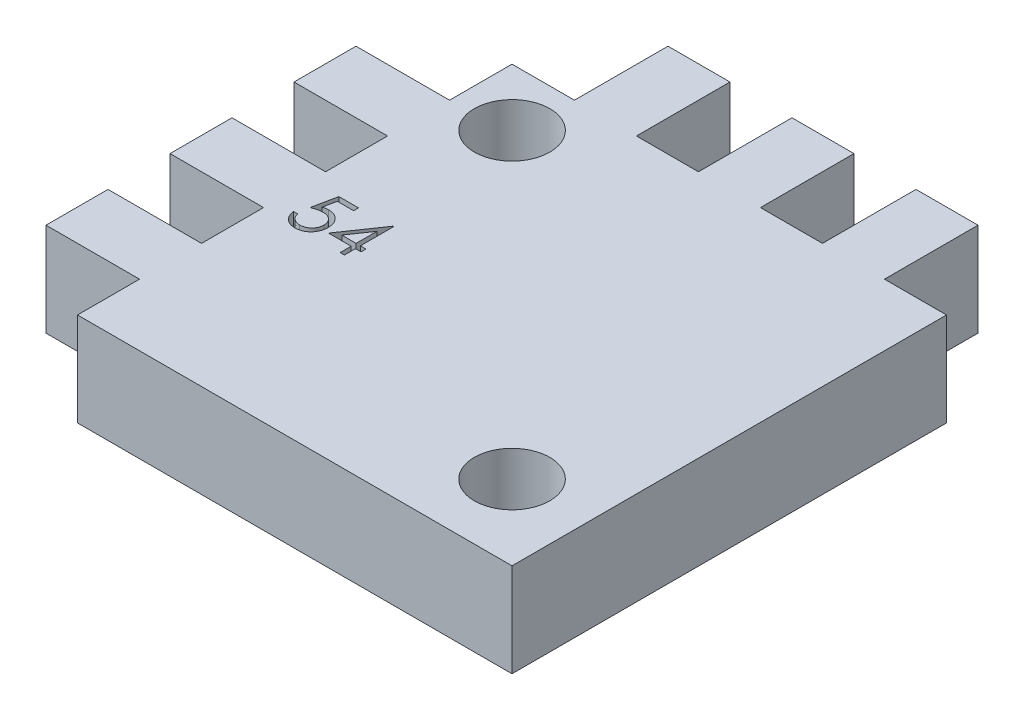
from build123d import *

# Parameters (mm, degrees)
SKETCH1_R           = 2.5
BOSS_EXTRUDE1_DEPTH = 6.2
CUT_EXTRUDE1_DEPTH  = 1


with BuildPart() as part:
    # Sketch1 → Boss-Extrude1 (new body)
    with BuildSketch(Plane(origin=(0, 0, 0), x_dir=(1, 0, 0), z_dir=(0, 1, 0))):
        Polygon((0, 24.66), (0, 20.55), (6.2, 20.55), (6.2, 16.44), (0, 16.44), (0, 12.33), (6.2, 12.33), (6.2, 8.22), (0, 8.22), (0, 4.11), (6.2, 4.11), (6.2, 0), (17, 0), (35, 0), (35, 18), (35, 28.8), (30.89, 28.8), (30.89, 35), (26.78, 35), (26.78, 28.8), (22.67, 28.8), (22.67, 35), (18.56, 35), (18.56, 28.8), (14.45, 28.8), (14.45, 35), (10.34, 35), (10.34, 28.8), (6.2, 28.8), (6.2, 24.66), align=None)
        with Locations((10.006, 25)):
            Circle(SKETCH1_R, mode=Mode.SUBTRACT)
        with Locations((30.02235364, 4.980572344)):
            Circle(SKETCH1_R, mode=Mode.SUBTRACT)
    extrude(amount=BOSS_EXTRUDE1_DEPTH)

    # Sketch2 → Cut-Extrude1 (cut)
    with BuildSketch(Plane(origin=(0, 6.2, 0), x_dir=(1, 0, 0), z_dir=(0, 1, 0))):
        with BuildLine():
            Line((9.367624272, 15.46006193), (9.367624272, 15.134420905))
            Line((9.367624272, 15.134420905), (8.28766634, 15.134420905))
            Line((8.28766634, 15.134420905), (8.116577598, 14.299329759))
            add(Edge.make_bspline(
                [(8.116577598, 14.299329759), (8.150192569, 14.308610077), (8.215316261, 14.326589225), (8.311436992, 14.346551603), (8.40268849, 14.358585256), (8.461902576, 14.360228373), (8.490555963, 14.361023469)],
                knots=[0, 0, 0, 0, 0.000104595, 0.000202637, 0.000294305, 0.000380252, 0.000380252, 0.000380252, 0.000380252], degree=3))
            add(Edge.make_bspline(
                [(8.490555963, 14.361023469), (8.526010498, 14.360256084), (8.595722973, 14.358747215), (8.697721161, 14.344258466), (8.795087428, 14.321452972), (8.88761815, 14.289593641), (8.975484506, 14.248854097), (9.05787808, 14.197963437), (9.136035615, 14.138515344), (9.208554968, 14.070166655), (9.274344876, 13.994944902), (9.332189738, 13.914065976), (9.381322945, 13.828315883), (9.420838773, 13.736875331), (9.452393133, 13.640755241), (9.4733953, 13.538944256), (9.487380458, 13.432402033), (9.488942908, 13.359554316), (9.489739657, 13.322406682)],
                knots=[0, 0, 0, 0, 0.000106308, 0.000209029, 0.000308378, 0.000405929, 0.000502102, 0.000598312, 0.00069588, 0.000796219, 0.000896736, 0.000995218, 0.001094066, 0.001192613, 0.001293582, 0.001396995, 0.001504047, 0.001615439, 0.001615439, 0.001615439, 0.001615439], degree=3))
            add(Edge.make_bspline(
                [(9.489739657, 13.322406682), (9.489136339, 13.296532954), (9.487937855, 13.245135158), (9.481843137, 13.168804347), (9.470108594, 13.094089491), (9.454353587, 13.020980679), (9.433904394, 12.94961632), (9.409149323, 12.879792148), (9.378854356, 12.811942755), (9.345624465, 12.745426146), (9.308208017, 12.681746072), (9.266680371, 12.622193063), (9.222805961, 12.56587375), (9.17559699, 12.51339215), (9.124614659, 12.465093126), (9.070476403, 12.420690042), (9.013614223, 12.379431978), (8.953148396, 12.342993687), (8.890426286, 12.309463005), (8.824542118, 12.281955225), (8.756995625, 12.257362103), (8.686814631, 12.237759175), (8.614158101, 12.222398929), (8.538906269, 12.211966241), (8.461453804, 12.204367616), (8.4089529, 12.203891949), (8.382432966, 12.203651674)],
                knots=[0, 0, 0, 0, 7.7636e-05, 0.000154223, 0.000229512, 0.000304362, 0.000378447, 0.000452077, 0.000526407, 0.000601214, 0.00067506, 0.000747747, 0.00081887, 0.000889121, 0.000959302, 0.001029336, 0.001099058, 0.00116985, 0.001240974, 0.00131221, 0.00138383, 0.001456517, 0.001530612, 0.001606437, 0.001684346, 0.001763871, 0.001763871, 0.001763871, 0.001763871], degree=3))
            add(Edge.make_bspline(
                [(8.382432966, 12.203651674), (8.350797102, 12.204278363), (8.288557277, 12.205511299), (8.197370763, 12.218409496), (8.109636799, 12.236882477), (8.026061636, 12.264673951), (7.945896275, 12.299496711), (7.870219953, 12.343507809), (7.797098999, 12.393381711), (7.729505937, 12.452237459), (7.666771462, 12.516568114), (7.610613415, 12.586379688), (7.560599385, 12.660519968), (7.517530286, 12.739349008), (7.480792795, 12.822659675), (7.451932056, 12.910764112), (7.428638119, 13.003201972), (7.418783445, 13.066841228), (7.413778118, 13.099164495)],
                knots=[0, 0, 0, 0, 9.4843e-05, 0.000186593, 0.000275792, 0.000363484, 0.000450342, 0.000537514, 0.000625728, 0.000715478, 0.000805885, 0.000894984, 0.00098389, 0.001073836, 0.001164117, 0.001256635, 0.001351658, 0.001449737, 0.001449737, 0.001449737, 0.001449737], degree=3))
            Line((7.413778118, 13.099164495), (7.698714016, 13.099164495))
            add(Edge.make_bspline(
                [(7.698714016, 13.099164495), (7.705724921, 13.068887284), (7.719200271, 13.010692804), (7.748778343, 12.928930802), (7.784942388, 12.856069792), (7.827944904, 12.791145956), (7.87924386, 12.73453208), (7.93778127, 12.684079459), (8.003410991, 12.638563449), (8.076339135, 12.600624224), (8.153276714, 12.56826757), (8.233801254, 12.546721389), (8.315720197, 12.531571293), (8.371127004, 12.530054768), (8.398969424, 12.5292927)],
                knots=[0, 0, 0, 0, 9.3172e-05, 0.000179081, 0.000260145, 0.000336703, 0.000411917, 0.000488562, 0.000568128, 0.000650923, 0.00073478, 0.000817953, 0.000900557, 0.000983994, 0.000983994, 0.000983994, 0.000983994], degree=3))
            add(Edge.make_bspline(
                [(8.398969424, 12.5292927), (8.426146013, 12.530037262), (8.479656939, 12.531503313), (8.558407269, 12.542787274), (8.634437519, 12.560165928), (8.706997478, 12.586173582), (8.777356875, 12.617782719), (8.843735938, 12.658345681), (8.908054976, 12.705027269), (8.968314783, 12.758509355), (9.023504855, 12.817446149), (9.072269336, 12.880472071), (9.112888394, 12.947706638), (9.147118621, 13.017985856), (9.173111256, 13.092079975), (9.191654146, 13.169641756), (9.202542635, 13.250862773), (9.204040492, 13.306261362), (9.204803759, 13.334491017)],
                knots=[0, 0, 0, 0, 8.15e-05, 0.000160473, 0.000238226, 0.000315066, 0.000391338, 0.000469218, 0.000547964, 0.000629516, 0.000710512, 0.000789892, 0.000868102, 0.000945761, 0.001024012, 0.00110315, 0.001184644, 0.001269321, 0.001269321, 0.001269321, 0.001269321], degree=3))
            add(Edge.make_bspline(
                [(9.204803759, 13.334491017), (9.204206424, 13.359959735), (9.203037226, 13.409811125), (9.193484495, 13.482744691), (9.176868384, 13.551753808), (9.153805293, 13.61717172), (9.124523168, 13.679060129), (9.088739728, 13.737482905), (9.045783431, 13.791670025), (8.996714361, 13.841646841), (8.942958852, 13.887770406), (8.883592028, 13.927089685), (8.819856238, 13.960167667), (8.752519387, 13.988713637), (8.6799798, 14.009215742), (8.603673998, 14.024608038), (8.522777984, 14.033511974), (8.46746886, 14.034747402), (8.439038535, 14.035382443)],
                knots=[0, 0, 0, 0, 7.6388e-05, 0.000149519, 0.000220172, 0.000288967, 0.000357247, 0.000425206, 0.000494043, 0.000564207, 0.000635056, 0.000706145, 0.000777268, 0.000850264, 0.000925136, 0.001002969, 0.001083601, 0.001168886, 0.001168886, 0.001168886, 0.001168886], degree=3))
            add(Edge.make_bspline(
                [(8.439038535, 14.035382443), (8.414428721, 14.034855764), (8.363615699, 14.033768305), (8.28567142, 14.025761412), (8.203763929, 14.012844338), (8.118207208, 13.995076813), (8.028744318, 13.971825765), (7.935564055, 13.943963325), (7.838470499, 13.910651226), (7.77304942, 13.885494147), (7.739419144, 13.87256193)],
                knots=[0, 0, 0, 0, 7.3822e-05, 0.000152423, 0.000234822, 0.000322511, 0.00041445, 0.000512043, 0.000614219, 0.000722306, 0.000722306, 0.000722306, 0.000722306], degree=3))
            Line((7.739419144, 13.87256193), (8.06506017, 15.46006193))
            Line((8.06506017, 15.46006193), (9.367624272, 15.46006193))
        make_face()
        Polygon((11.548528719, 15.541472187), (11.606406324, 15.541472187), (11.606406324, 13.343395264), (11.972752477, 13.343395264), (11.972752477, 13.017754238), (11.606406324, 13.017754238), (11.606406324, 12.28506193), (11.321470426, 12.28506193), (11.321470426, 13.017754238), (9.815380682, 13.017754238), align=None)
        Polygon((11.321470426, 13.343395264), (11.321470426, 14.722281482), (10.375076195, 13.343395264), align=None, mode=Mode.SUBTRACT)
    extrude(amount=-CUT_EXTRUDE1_DEPTH, mode=Mode.SUBTRACT)


solid = part.part
